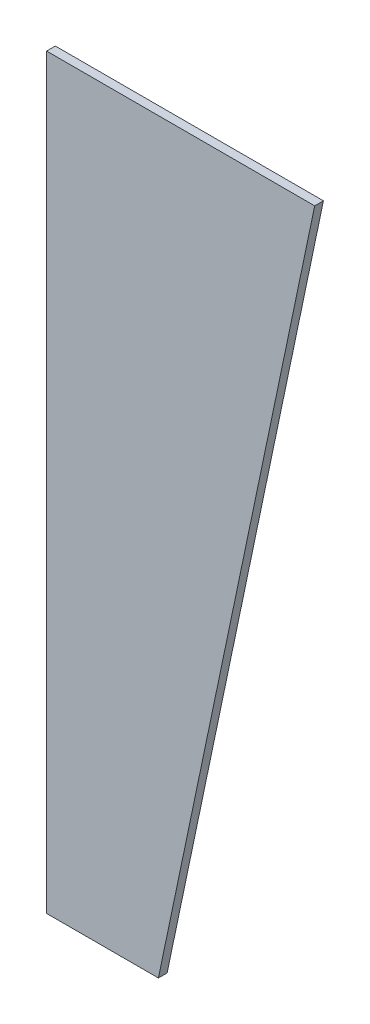
from build123d import *

# Parameters (mm, degrees)
BOSS_EXTRUDE1_DEPTH = 3


with BuildPart() as part:
    # Sketch1 → Boss-Extrude1 (new body)
    with BuildSketch(Plane.XY):
        Polygon((0, 257), (92.26, 257), (38.48, 0), (0, 0), align=None)
    extrude(amount=BOSS_EXTRUDE1_DEPTH)


solid = part.part
